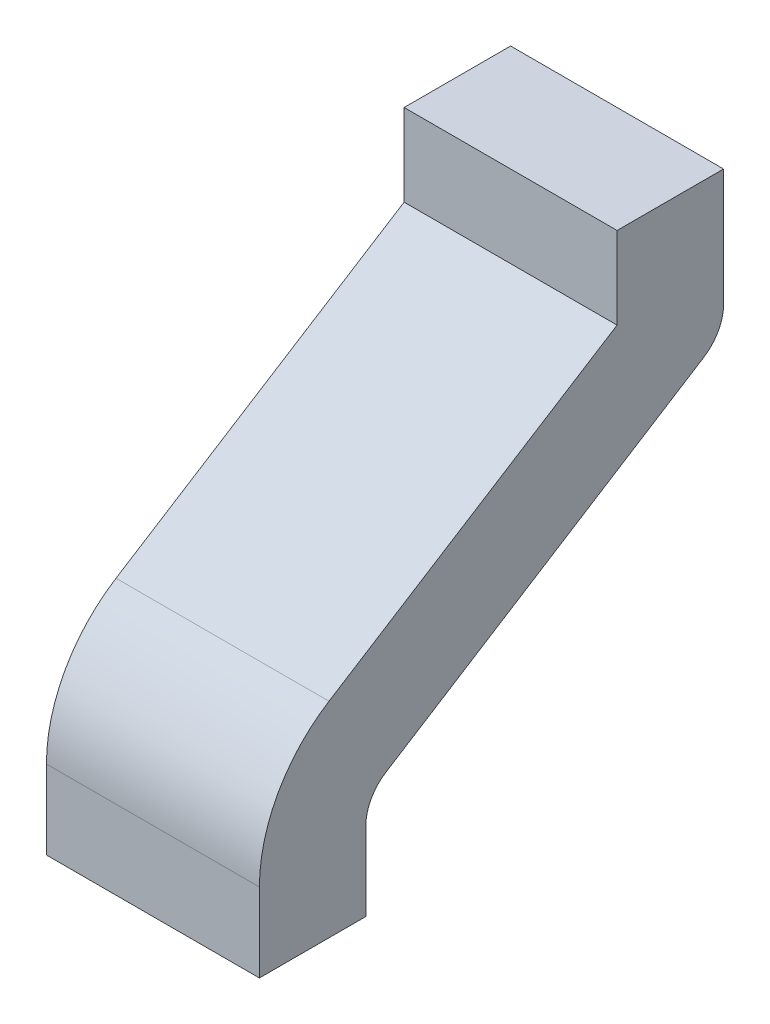
from build123d import *

# Parameters (mm, degrees)
BOSS_EXTRU_1_DEPTH = 0.5


with BuildPart() as part:
    # Esquisse1 → Boss.-Extru.1 (new body)
    with BuildSketch(Plane.ZY):
        with BuildLine():
            Line((0.65, 4), (0.65, 4.185012068))
            ThreePointArc((0.65, 4.185012068), (0.637559943, 4.23331586), (0.603334874, 4.269601613))
            Line((0.603334874, 4.269601613), (-0.143023698, 4.740190977))
            ThreePointArc((-0.143023698, 4.740190977), (-0.177248768, 4.776476731), (-0.189688824, 4.824780523))
            Line((-0.189688824, 4.824780523), (-0.189688824, 5.1))
            Line((-0.189688824, 5.1), (0.060311176, 5.1))
            Line((0.060311176, 5.1), (0.060311176, 4.907530334))
            Line((0.060311176, 4.907530334), (0.736672059, 4.481075477))
            ThreePointArc((0.736672059, 4.481075477), (0.856459802, 4.354075339), (0.9, 4.185012068))
            Line((0.9, 4.185012068), (0.9, 4))
            Line((0.9, 4), (0.65, 4))
        make_face()
    extrude(amount=BOSS_EXTRU_1_DEPTH)


solid = part.part
